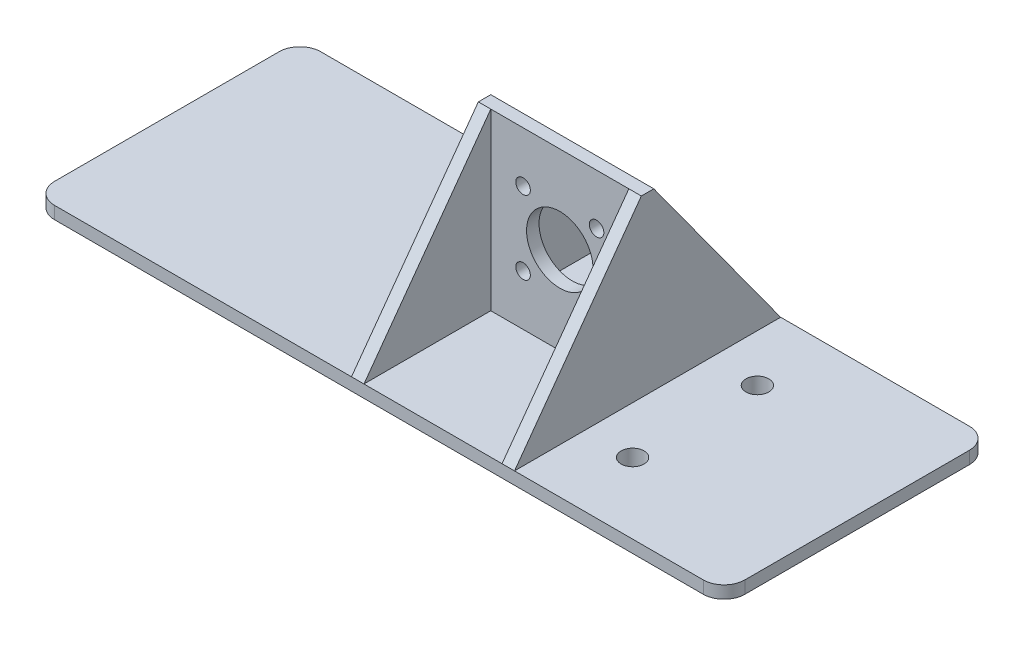
from build123d import *

# Parameters (mm, degrees)
BOSS_EXTRUDE1_DEPTH      = 3
SKETCH2_R                = 2.75
CUT_EXTRUDE1_DEPTH       = 4
SKETCH3_W                = 39.2
SKETCH3_H                = 3
BOSS_EXTRUDE2_DEPTH      = 42
SKETCH6_R                = 8
SKETCH6_R_2              = 1.75
CUT_EXTRUDE2_DEPTH       = 31.5
CUT_EXTRUDE2_DEPTH_BACK  = 34.5
SKETCH7_W                = 3
SKETCH7_H                = 42
BOSS_EXTRUDE3_DEPTH      = 30.5
BOSS_EXTRUDE3_DEPTH_BACK = 33.5
CUT_EXTRUDE5_DEPTH       = 77.4
CUT_EXTRUDE5_DEPTH_BACK  = 90.6
SKETCH9_R                = 4.75
SKETCH9_R_2              = 2.75
BOSS_EXTRUDE4_DEPTH      = 4.5


with BuildPart() as part:
    # Sketch1 → Boss-Extrude1 (new body)
    with BuildSketch(Plane(origin=(0, 0, 0), x_dir=(1, 0, 0), z_dir=(0, 1, 0))):
        with BuildLine():
            Line((78, 32), (-78, 32))
            ThreePointArc((-78, 32), (-81.535533906, 30.535533906), (-83, 27))
            Line((-83, 27), (-83, -27))
            ThreePointArc((-83, -27), (-81.535533906, -30.535533906), (-78, -32))
            Line((-78, -32), (78, -32))
            ThreePointArc((78, -32), (81.535533906, -30.535533906), (83, -27))
            Line((83, -27), (83, 27))
            ThreePointArc((83, 27), (81.535533906, 30.535533906), (78, 32))
        make_face()
    extrude(amount=BOSS_EXTRUDE1_DEPTH)

    # Sketch2 → Cut-Extrude1 (cut, through all)
    with BuildSketch(Plane(origin=(0, 3, 0), x_dir=(1, 0, 0), z_dir=(0, 1, 0))):
        with Locations((44, -15)):
            Circle(SKETCH2_R)
        with Locations((44, 15)):
            Circle(SKETCH2_R)
        with Locations((-18, 0)):
            Circle(SKETCH2_R)
    extrude(amount=-CUT_EXTRUDE1_DEPTH, mode=Mode.SUBTRACT)

    # Sketch3 → Boss-Extrude2 (add)
    with BuildSketch(Plane(origin=(0, 3, 0), x_dir=(1, 0, 0), z_dir=(0, 1, 0))):
        with Locations((13, 0)):
            Rectangle(SKETCH3_W, SKETCH3_H)
    extrude(amount=BOSS_EXTRUDE2_DEPTH)

    # Sketch6 → Cut-Extrude2 (cut, two sides)
    with BuildSketch(Plane(origin=(0, 0, -1.5), x_dir=(-1, 0, 0), z_dir=(0, 0, -1))) as cut_extrude2_sk:
        with Locations((-13, 24)):
            Circle(SKETCH6_R)
        with Locations((-4.161165235, 15.161165235)):
            Circle(SKETCH6_R_2)
        with Locations((-21.838834765, 15.161165235)):
            Circle(SKETCH6_R_2)
        with Locations((-21.838834765, 32.838834765)):
            Circle(SKETCH6_R_2)
        with Locations((-4.161165235, 32.838834765)):
            Circle(SKETCH6_R_2)
    extrude(amount=CUT_EXTRUDE2_DEPTH, mode=Mode.SUBTRACT)
    extrude(cut_extrude2_sk.sketch, amount=-CUT_EXTRUDE2_DEPTH_BACK, mode=Mode.SUBTRACT)

    # Sketch7 → Boss-Extrude3 (add, two sides)
    with BuildSketch(Plane(origin=(0, 0, -1.5), x_dir=(-1, 0, 0), z_dir=(0, 0, -1))) as boss_extrude3_sk:
        with Locations((-31.1, 24)):
            Rectangle(SKETCH7_W, SKETCH7_H)
        with Locations((5.1, 24)):
            Rectangle(SKETCH7_W, SKETCH7_H)
    extrude(amount=BOSS_EXTRUDE3_DEPTH)
    extrude(boss_extrude3_sk.sketch, amount=-BOSS_EXTRUDE3_DEPTH_BACK)

    # Sketch8 → Cut-Extrude5 (cut, two sides)
    with BuildSketch(Plane.ZY.offset(6.6)) as cut_extrude5_sk:
        Polygon((-1.5, 45), (-32, 3), (-32, 45), align=None)
        Polygon((1.5, 45), (32, 3), (32, 45), align=None)
    extrude(amount=CUT_EXTRUDE5_DEPTH, mode=Mode.SUBTRACT)
    extrude(cut_extrude5_sk.sketch, amount=-CUT_EXTRUDE5_DEPTH_BACK, mode=Mode.SUBTRACT)

    # Sketch9 → Boss-Extrude4 (add)
    with BuildSketch(Plane.XZ):
        with Locations((-18, 0)):
            Circle(SKETCH9_R)
        with Locations((-18, 0)):
            Circle(SKETCH9_R_2, mode=Mode.SUBTRACT)
        with Locations((44, -15)):
            Circle(SKETCH9_R)
        with Locations((44, -15)):
            Circle(SKETCH9_R_2, mode=Mode.SUBTRACT)
        with Locations((44, 15)):
            Circle(SKETCH9_R)
        with Locations((44, 15)):
            Circle(SKETCH9_R_2, mode=Mode.SUBTRACT)
    extrude(amount=BOSS_EXTRUDE4_DEPTH)


solid = part.part
